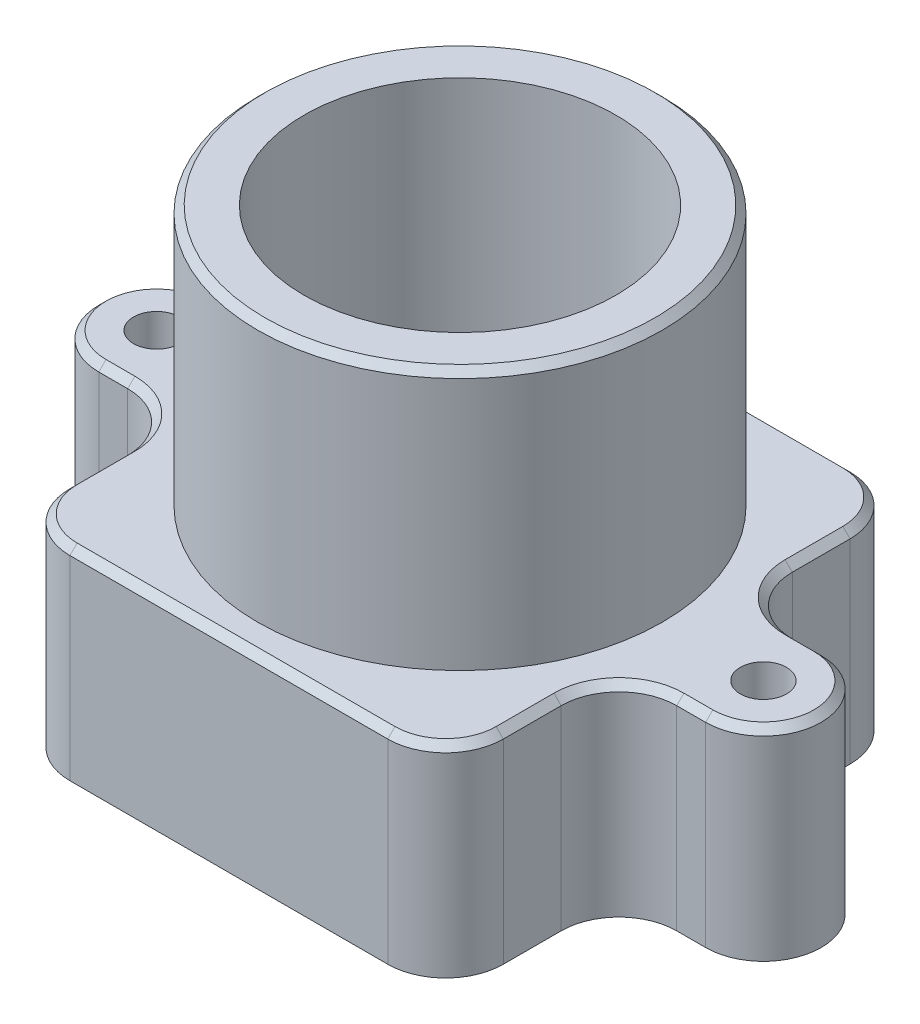
from build123d import *

# Parameters (mm, degrees)
BOSS_EXTRUDE1_DEPTH     = 7
FILLET1_R               = 2
M2X0_4_TAPPED_HOLE1_D   = 1.6
CHAMFER1_SIZE           = 0.25
SKETCH4_R               = 7
BOSS_EXTRUDE2_DEPTH     = 9
CHAMFER2_SIZE           = 0.25
M12X1_25_TAPPED_HOLE1_D = 10.8


with BuildPart() as part:
    # Sketch1 → Boss-Extrude1 (new body)
    with BuildSketch(Plane(origin=(0, 0, 0), x_dir=(1, 0, 0), z_dir=(0, 1, 0))):
        with BuildLine():
            Line((-7.5, 8), (7.5, 8))
            Line((7.5, 8), (7.5, 2))
            Line((7.5, 2), (10.5, 2))
            ThreePointArc((10.5, 2), (12.5, 0), (10.5, -2))
            Line((10.5, -2), (7.5, -2))
            Line((7.5, -2), (7.5, -8))
            Line((7.5, -8), (-7.5, -8))
            Line((-7.5, -8), (-7.5, -2))
            Line((-7.5, -2), (-10.5, -2))
            ThreePointArc((-10.5, -2), (-12.5, 0), (-10.5, 2))
            Line((-10.5, 2), (-7.5, 2))
            Line((-7.5, 2), (-7.5, 8))
        make_face()
    extrude(amount=BOSS_EXTRUDE1_DEPTH)

    # Fillet1
    fillet1_edges = [part.edges().sort_by_distance(p)[0] for p in [
        (7.5, 3.5, 8),
        (-7.5, 3.5, 8),
        (-7.5, 3.5, 2),
        (-7.5, 3.5, -2),
        (-7.5, 3.5, -8),
        (7.5, 3.5, -8),
        (7.5, 3.5, -2),
        (7.5, 3.5, 2),
    ]]
    fillet(fillet1_edges, radius=FILLET1_R)

    # M2x0.4 Tapped Hole1 (through all)
    with Locations(Plane(origin=(0, 7, 0), x_dir=(1, 0, 0), z_dir=(0, 1, 0))):
        with Locations((10.5, 0), (-10.5, 0)):
            Hole(M2X0_4_TAPPED_HOLE1_D / 2)

    # Chamfer1
    chamfer1_edges = [part.edges().sort_by_distance(p)[0] for p in [
        (12.5, 7, 0),
        (10, 7, -2),
        (-12.5, 7, 0),
        (-10, 7, 2),
        (7.5, 7, -5),
        (0, 7, -8),
        (7.5, 7, 5),
        (10, 7, 2),
        (-7.5, 7, -5),
        (-10, 7, -2),
        (-7.5, 7, 5),
        (0, 7, 8),
        (6.914213562, 7, 7.414213562),
        (-6.914213562, 7, 7.414213562),
        (-6.914213562, 7, -7.414213562),
        (6.914213562, 7, -7.414213562),
        (8.085786438, 7, -2.585786438),
        (-8.085786438, 7, -2.585786438),
        (-8.085786438, 7, 2.585786438),
        (8.085786438, 7, 2.585786438),
    ]]
    chamfer(chamfer1_edges, length=CHAMFER1_SIZE)

    # Sketch4 → Boss-Extrude2 (add)
    with BuildSketch(Plane(origin=(0, 7, 0), x_dir=(1, 0, 0), z_dir=(0, 1, 0))):
        Circle(SKETCH4_R)
    extrude(amount=BOSS_EXTRUDE2_DEPTH)

    # Chamfer2
    chamfer2_edges = [part.edges().sort_by_distance(p)[0] for p in [
        (-7, 16, 0),
    ]]
    chamfer(chamfer2_edges, length=CHAMFER2_SIZE)

    # M12x1.25 Tapped Hole1 (through all)
    with Locations(Plane(origin=(0, 16, 0), x_dir=(1, 0, 0), z_dir=(0, 1, 0))):
        with Locations((0, 0)):
            Hole(M12X1_25_TAPPED_HOLE1_D / 2)


solid = part.part
